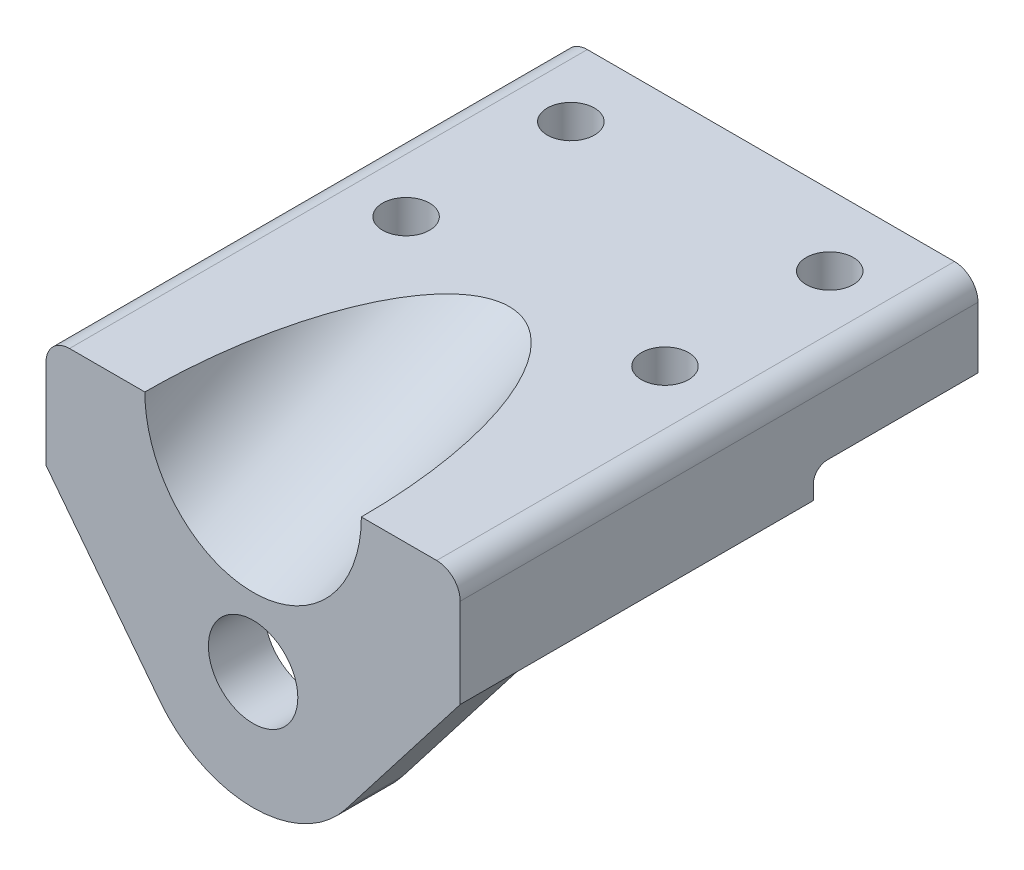
from build123d import *

# Parameters (mm, degrees)
SKETCH1_W               = 88
SKETCH1_H               = 110
BOSS_EXTRUDE1_DEPTH     = 18
SKETCH2_W               = 88
SKETCH2_H               = 75
BOSS_EXTRUDE2_DEPTH     = 6
SKETCH3_R               = 9.5
BOSS_EXTRUDE3_DEPTH     = 12
FILLET1_R               = 3
FILLET2_R               = 5
SKETCH5_R               = 5
CUT_EXTRUDE1_DEPTH      = 1
CUT_EXTRUDE1_DEPTH_BACK = 66


with BuildPart() as part:
    # Sketch1 → Boss-Extrude1 (new body)
    with BuildSketch(Plane(origin=(0, 0, 0), x_dir=(1, 0, 0), z_dir=(0, 1, 0))):
        Rectangle(SKETCH1_W, SKETCH1_H)
    extrude(amount=BOSS_EXTRUDE1_DEPTH)

    # Sketch2 → Boss-Extrude2 (add)
    with BuildSketch(Plane.XZ):
        with Locations((0, 17.5)):
            Rectangle(SKETCH2_W, SKETCH2_H)
    extrude(amount=BOSS_EXTRUDE2_DEPTH)

    # Sketch3 → Boss-Extrude3 (add)
    with BuildSketch(Plane.XY.offset(55)):
        with BuildLine():
            Line((-44, -6), (-19.769224603, -37.302867659))
            ThreePointArc((-19.769224603, -37.302867659), (0, -47), (19.769224603, -37.302867659))
            Line((19.769224603, -37.302867659), (44, -6))
            Line((44, -6), (-44, -6))
        make_face()
        with Locations((0, -22)):
            Circle(SKETCH3_R, mode=Mode.SUBTRACT)
    extrude(amount=-BOSS_EXTRUDE3_DEPTH)

    # Fillet1
    fillet1_edges = [part.edges().sort_by_distance(p)[0] for p in [
        (0, 0, -20),
    ]]
    fillet(fillet1_edges, radius=FILLET1_R)

    # Sketch4 → Cut-Revolve1 (revolve, cut)
    with BuildSketch(Plane(origin=(0, 0, 0), x_dir=(0, 0, -1), z_dir=(1, 0, 0))):
        Polygon((-55, -7.377692136), (-0.577363587, 18), (-0.577363587, 43.377692136), (-55, 18), align=None)
    revolve(axis=Axis((0, 18, 55), (0, 0.422618262, -0.906307787)), mode=Mode.SUBTRACT)

    # Fillet2
    fillet2_edges = [part.edges().sort_by_distance(p)[0] for p in [
        (-44, 18, 0),
        (44, 18, 0),
    ]]
    fillet(fillet2_edges, radius=FILLET2_R)

    # Sketch5 → Cut-Extrude1 (cut, two sides)
    with BuildSketch(Plane(origin=(0, 18, 0), x_dir=(1, 0, 0), z_dir=(0, 1, 0))) as cut_extrude1_sk:
        with Locations((-27.5, 40)):
            Circle(SKETCH5_R)
        with Locations((27.5, 40)):
            Circle(SKETCH5_R)
        with Locations((27.5, 5)):
            Circle(SKETCH5_R)
        with Locations((-27.5, 5)):
            Circle(SKETCH5_R)
    extrude(amount=CUT_EXTRUDE1_DEPTH, mode=Mode.SUBTRACT)
    extrude(cut_extrude1_sk.sketch, amount=-CUT_EXTRUDE1_DEPTH_BACK, mode=Mode.SUBTRACT)


solid = part.part
